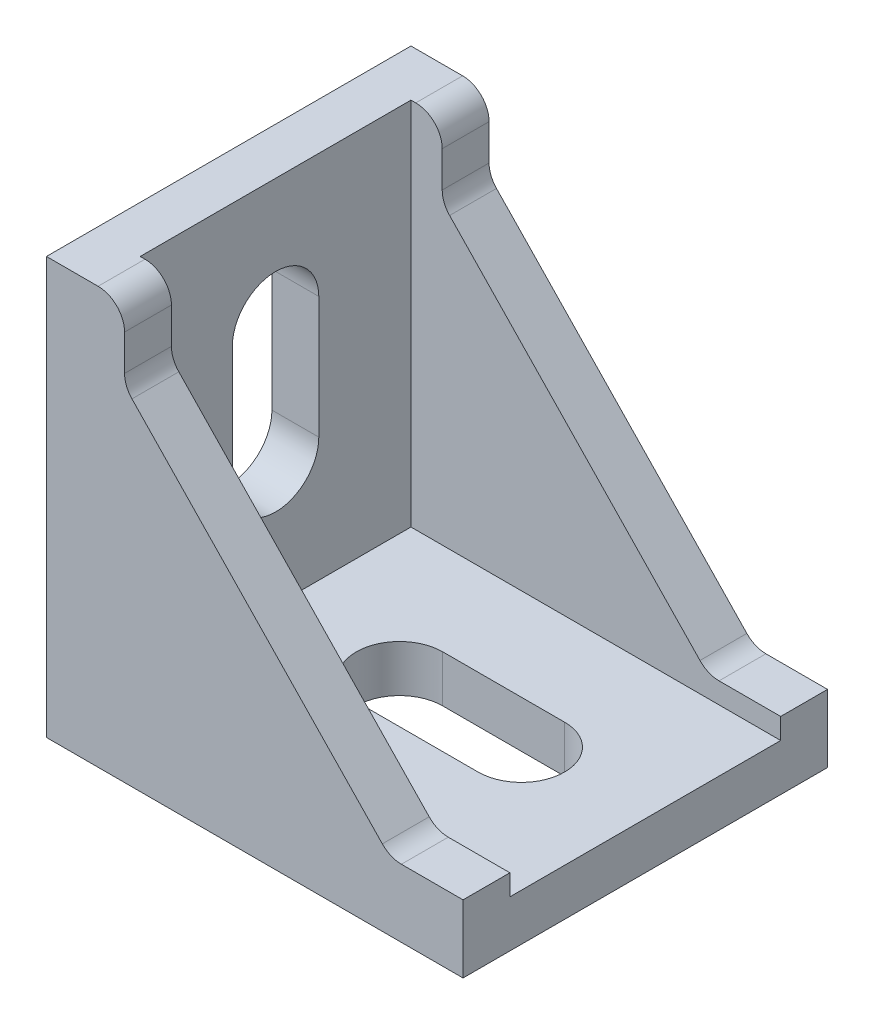
from build123d import *

# Parameters (mm, degrees)
BOSS_EXTRUDE1_DEPTH = 17.5
BOSS_EXTRUDE2_DEPTH = 4.5
CUT_EXTRUDE1_DEPTH  = 5.5
CUT_EXTRUDE2_DEPTH  = 5.5
FILLET1_R           = 2.54


with BuildPart() as part:
    # Sketch1 → Boss-Extrude1 (new body, symmetric)
    with BuildSketch(Plane.XY):
        Polygon((-20, 17.75), (-15.5, 17.75), (-15.5, -17.75), (20, -17.75), (20, -22.25), (-20, -22.25), align=None)
    extrude(amount=BOSS_EXTRUDE1_DEPTH, both=True)

    # Sketch2 → Boss-Extrude2 (add)
    with BuildSketch(Plane.XY.offset(17.5)):
        Polygon((-15.5, 17.75), (-12.5, 17.75), (-12.5, 10.75), (13, -15.75), (20, -15.75), (20, -17.75), (-15.5, -17.75), align=None)
    boss_extrude2 = extrude(amount=-BOSS_EXTRUDE2_DEPTH)

    # Mirror1: Boss-Extrude2 across plane
    add(boss_extrude2.mirror(Plane.XY))

    # Sketch3 → Cut-Extrude1 (cut, through all)
    with BuildSketch(Plane(origin=(-15.5, 0, 0), x_dir=(0, 0, -1), z_dir=(1, 0, 0))):
        with BuildLine():
            Line((4.15, 5.85), (4.15, -5.85))
            ThreePointArc((4.15, -5.85), (0, -10), (-4.15, -5.85))
            Line((-4.15, -5.85), (-4.15, 5.85))
            ThreePointArc((-4.15, 5.85), (0, 10), (4.15, 5.85))
        make_face()
    extrude(amount=-CUT_EXTRUDE1_DEPTH, mode=Mode.SUBTRACT)

    # Sketch4 → Cut-Extrude2 (cut, through all)
    with BuildSketch(Plane(origin=(0, -17.75, 0), x_dir=(1, 0, 0), z_dir=(0, 1, 0))):
        with BuildLine():
            Line((-3.6, 4.15), (8.1, 4.15))
            ThreePointArc((8.1, 4.15), (12.25, 0), (8.1, -4.15))
            Line((8.1, -4.15), (-3.6, -4.15))
            ThreePointArc((-3.6, -4.15), (-7.75, 0), (-3.6, 4.15))
        make_face()
    extrude(amount=-CUT_EXTRUDE2_DEPTH, mode=Mode.SUBTRACT)

    # Fillet1
    fillet1_edges = [part.edges().sort_by_distance(p)[0] for p in [
        (-12.5, 17.75, 15.25),
        (-12.5, 10.75, 15.25),
        (13, -15.75, 15.25),
        (13, -15.75, -15.25),
        (-12.5, 10.75, -15.25),
        (-12.5, 17.75, -15.25),
    ]]
    fillet(fillet1_edges, radius=FILLET1_R)


solid = part.part
